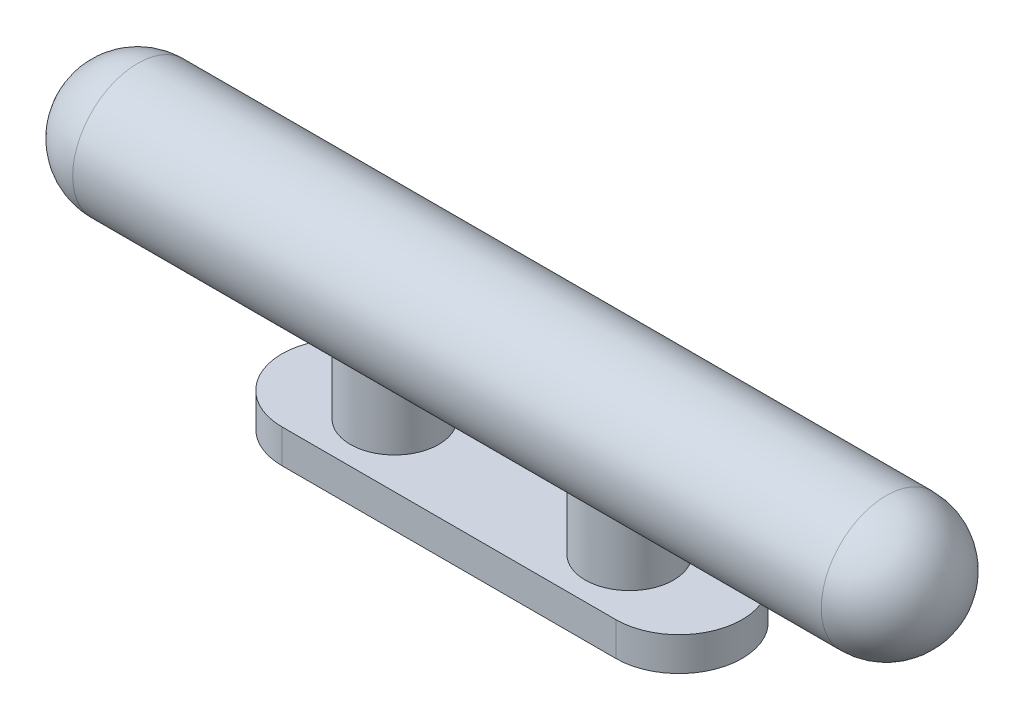
from build123d import *

# Parameters (mm, degrees)
BOSS_EXTRUDE1_DEPTH = 5.842
SKETCH2_R           = 7.6708
BOSS_EXTRUDE2_DEPTH = 14.224


with BuildPart() as part:
    # Sketch1 → Boss-Extrude1 (new body)
    with BuildSketch(Plane(origin=(0, 0, 0), x_dir=(1, 0, 0), z_dir=(0, 1, 0))):
        with BuildLine():
            Line((0, 10.95375), (57.9374, 10.95375))
            ThreePointArc((57.9374, 10.95375), (68.89115, 0), (57.9374, -10.95375))
            Line((57.9374, -10.95375), (0, -10.95375))
            ThreePointArc((0, -10.95375), (-10.95375, 0), (0, 10.95375))
        make_face()
    extrude(amount=BOSS_EXTRUDE1_DEPTH)

    # Sketch2 → Boss-Extrude2 (add)
    with BuildSketch(Plane(origin=(0, 5.842, 0), x_dir=(1, 0, 0), z_dir=(0, 1, 0))):
        with Locations((8.5979, 0)):
            Circle(SKETCH2_R)
        with Locations((49.3395, 0)):
            Circle(SKETCH2_R)
    extrude(amount=BOSS_EXTRUDE2_DEPTH)

    # Sketch3 → Revolve6 (revolve)
    with BuildSketch(Plane(origin=(0, 25.7048, 0), x_dir=(1, 0, 0), z_dir=(0, 1, 0))):
        with BuildLine():
            Line((-35.9537, -11.2776), (93.8911, -11.2776))
            ThreePointArc((93.8911, -11.2776), (101.865567436, -7.974467436), (105.1687, 0))
            Line((105.1687, 0), (-47.2313, 0))
            ThreePointArc((-47.2313, 0), (-43.928167436, -7.974467436), (-35.9537, -11.2776))
        make_face()
    revolve(axis=Axis((-35.9537, 25.7048, 0), (1, 0, 0)))


solid = part.part
